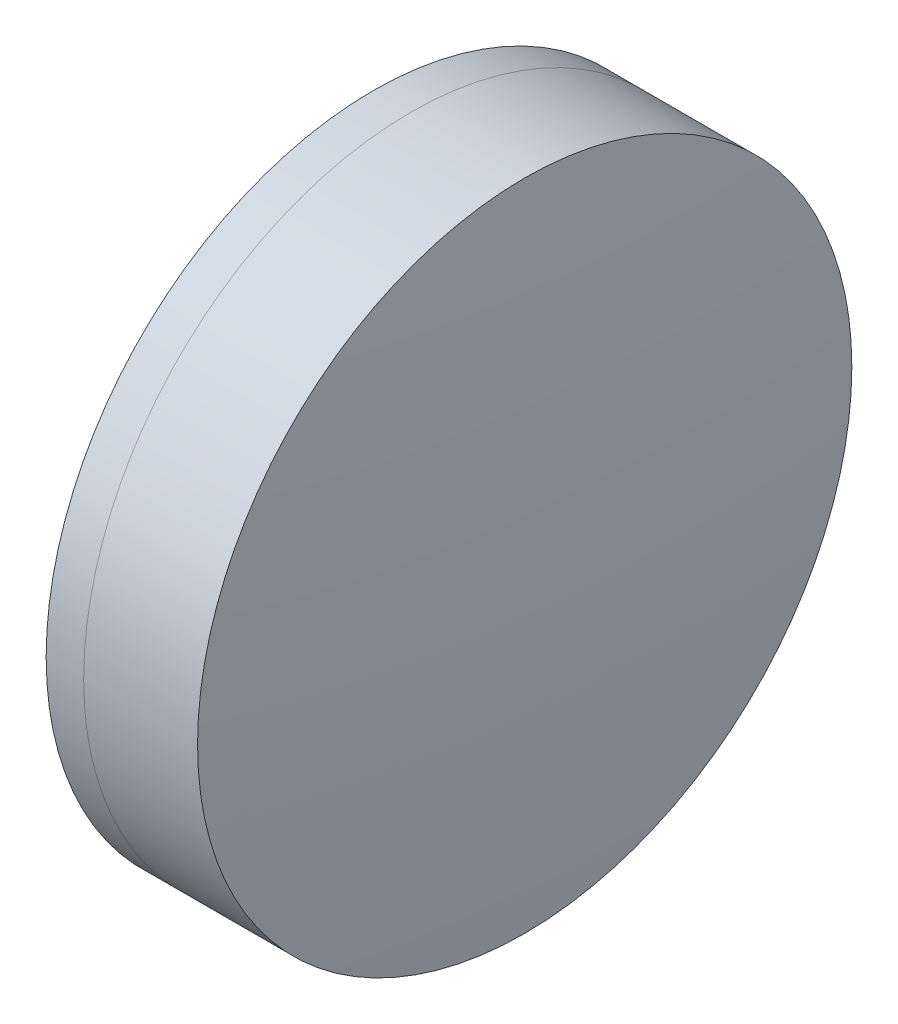
from build123d import *


with BuildPart() as part:
    # 草图1 one side → 旋转1 (revolve)
    with BuildSketch(Plane(origin=(0, 0, 0), x_dir=(1, 0, 0), z_dir=(0, 1, 0)), mode=Mode.PRIVATE) as revolve_1_sk:
        with BuildLine():
            ThreePointArc((284.615696838, 12.7), (282.459752255, 6.511971596), (281.728986555, 0))
            Line((281.728986555, 0), (289.528986555, 0))
            ThreePointArc((289.528986555, 0), (288.649019247, 6.581186795), (286.070941075, 12.7))
            Line((286.070941075, 12.7), (284.615696838, 12.7))
        make_face()
    revolve(revolve_1_sk.sketch.rotate(Axis((124.523309526, 0, 0), (1, 0, 0)), 180), axis=Axis((124.523309526, 0, 0), (1, 0, 0)))  # turned: the seam where the file's is


with BuildPart() as body_2:
    # 草图2 one side → 旋转3 (revolve)
    with BuildSketch(Plane(origin=(0, 0, 0), x_dir=(1, 0, 0), z_dir=(0, 1, 0)), mode=Mode.PRIVATE) as revolve_3_sk:
        with BuildLine():
            Line((290.492693192, 12.7), (286.070941075, 12.7))
            ThreePointArc((286.070941075, 12.7), (288.649019247, 6.581186795), (289.528986555, 0))
            Line((289.528986555, 0), (291.128986555, 0))
            ThreePointArc((291.128986555, 0), (290.969813513, 6.357964872), (290.492693192, 12.7))
        make_face()
    revolve(revolve_3_sk.sketch.rotate(Axis((-0.551919993, 0, 0), (1, 0, 0)), 180), axis=Axis((-0.551919993, 0, 0), (1, 0, 0)))  # turned: the seam where the file's is


solid = Compound([part.part, body_2.part])
